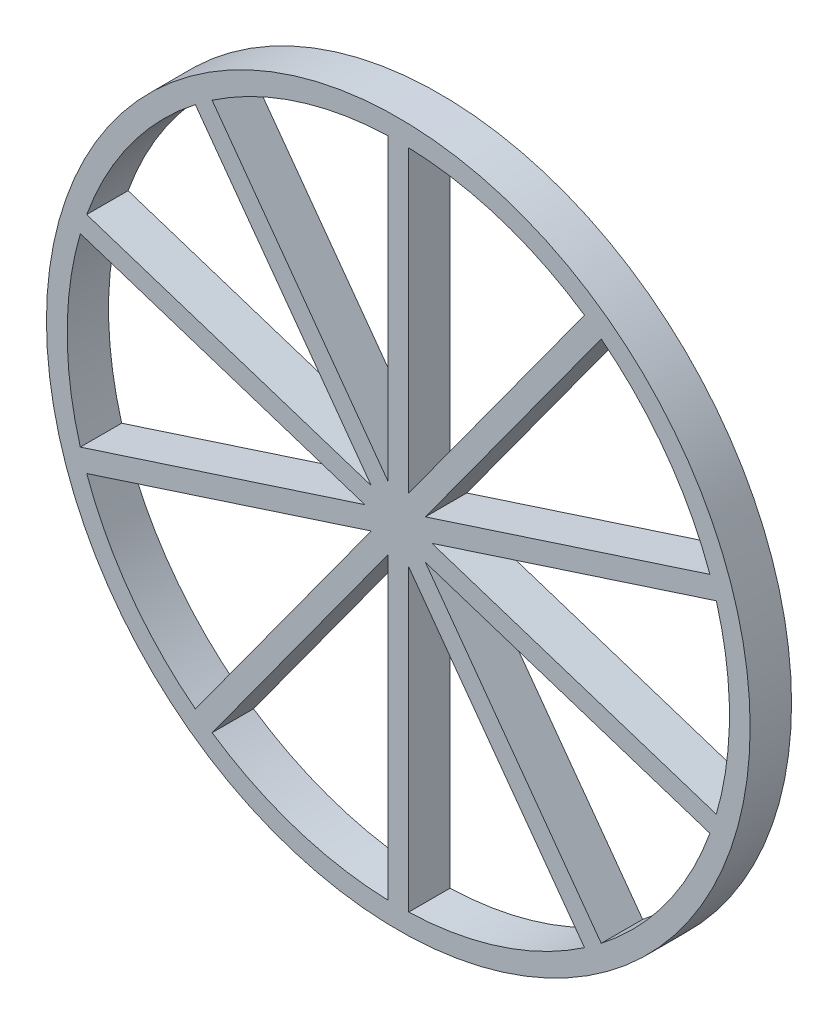
from build123d import *

# Parameters (mm, degrees)
ESBO_O1_R                = 8.5
RESSALTO_EXTRUS_O1_DEPTH = 1


with BuildPart() as part:
    # Esboço1 → Ressalto-extrusão1 (new body)
    with BuildSketch(Plane.XY):
        Circle(ESBO_O1_R)
        with BuildLine():
            Line((-0.654508497, 0.475528258), (-4.90223967, 6.322028647))
            ThreePointArc((-4.90223967, 6.322028647), (-6.472135955, 4.702282018), (-7.52748191, 2.708692692))
            Line((-7.52748191, 2.708692692), (-0.654508497, 0.475528258))
        make_face(mode=Mode.SUBTRACT)
        with BuildLine():
            Line((-0.25, 0.769420884), (-0.25, 7.996092796))
            ThreePointArc((-0.25, 7.996092796), (-2.472135955, 7.60845213), (-4.497731173, 6.615921274))
            Line((-4.497731173, 6.615921274), (-0.25, 0.769420884))
        make_face(mode=Mode.SUBTRACT)
        with BuildLine():
            Line((0.25, 0.769420884), (4.497731173, 6.615921274))
            ThreePointArc((4.497731173, 6.615921274), (2.472135955, 7.60845213), (0.25, 7.996092796))
            Line((0.25, 7.996092796), (0.25, 0.769420884))
        make_face(mode=Mode.SUBTRACT)
        with BuildLine():
            Line((0.654508497, 0.475528258), (7.52748191, 2.708692692))
            ThreePointArc((7.52748191, 2.708692692), (6.472135955, 4.702282018), (4.90223967, 6.322028647))
            Line((4.90223967, 6.322028647), (0.654508497, 0.475528258))
        make_face(mode=Mode.SUBTRACT)
        with BuildLine():
            Line((0.809016994, 0), (7.681990407, -2.233164433))
            ThreePointArc((7.681990407, -2.233164433), (8, 0), (7.681990407, 2.233164433))
            Line((7.681990407, 2.233164433), (0.809016994, 0))
        make_face(mode=Mode.SUBTRACT)
        with BuildLine():
            Line((0.654508497, -0.475528258), (4.90223967, -6.322028647))
            ThreePointArc((4.90223967, -6.322028647), (6.472135955, -4.702282018), (7.52748191, -2.708692692))
            Line((7.52748191, -2.708692692), (0.654508497, -0.475528258))
        make_face(mode=Mode.SUBTRACT)
        with BuildLine():
            Line((0.25, -0.769420884), (0.25, -7.996092796))
            ThreePointArc((0.25, -7.996092796), (2.472135955, -7.60845213), (4.497731173, -6.615921274))
            Line((4.497731173, -6.615921274), (0.25, -0.769420884))
        make_face(mode=Mode.SUBTRACT)
        with BuildLine():
            Line((-0.25, -0.769420884), (-4.497731173, -6.615921274))
            ThreePointArc((-4.497731173, -6.615921274), (-2.472135955, -7.60845213), (-0.25, -7.996092796))
            Line((-0.25, -7.996092796), (-0.25, -0.769420884))
        make_face(mode=Mode.SUBTRACT)
        with BuildLine():
            Line((-0.654508497, -0.475528258), (-7.52748191, -2.708692692))
            ThreePointArc((-7.52748191, -2.708692692), (-6.472135955, -4.702282018), (-4.90223967, -6.322028647))
            Line((-4.90223967, -6.322028647), (-0.654508497, -0.475528258))
        make_face(mode=Mode.SUBTRACT)
        with BuildLine():
            Line((-0.809016994, 0), (-7.681990407, 2.233164433))
            ThreePointArc((-7.681990407, 2.233164433), (-8, 0), (-7.681990407, -2.233164433))
            Line((-7.681990407, -2.233164433), (-0.809016994, 0))
        make_face(mode=Mode.SUBTRACT)
    extrude(amount=RESSALTO_EXTRUS_O1_DEPTH)


solid = part.part
